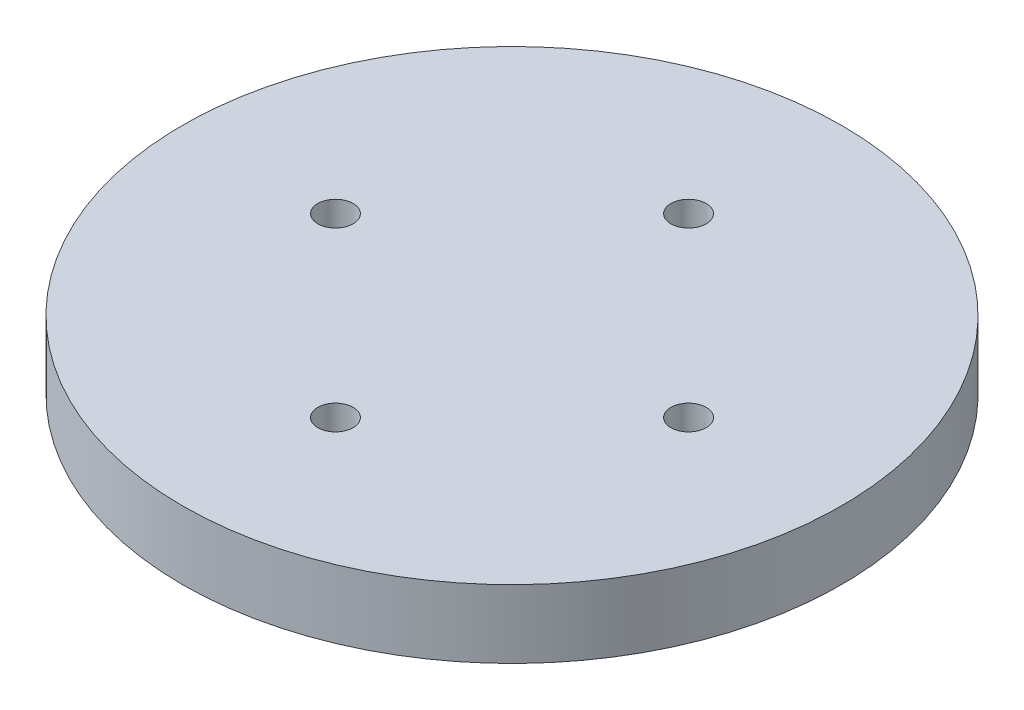
from build123d import *

# Parameters (mm, degrees)
ESQUISSE1_R        = 28
ESQUISSE1_R_2      = 1.5
BOSS_EXTRU_1_DEPTH = 5.8


with BuildPart() as part:
    # Esquisse1 → Boss.-Extru.1 (new body)
    with BuildSketch(Plane(origin=(0, 0, 0), x_dir=(1, 0, 0), z_dir=(0, 1, 0))):
        Circle(ESQUISSE1_R)
        with Locations((0, 15)):
            Circle(ESQUISSE1_R_2, mode=Mode.SUBTRACT)
        with Locations((15, 0)):
            Circle(ESQUISSE1_R_2, mode=Mode.SUBTRACT)
        with Locations((0, -15)):
            Circle(ESQUISSE1_R_2, mode=Mode.SUBTRACT)
        with Locations((-15, 0)):
            Circle(ESQUISSE1_R_2, mode=Mode.SUBTRACT)
    extrude(amount=BOSS_EXTRU_1_DEPTH)


solid = part.part
